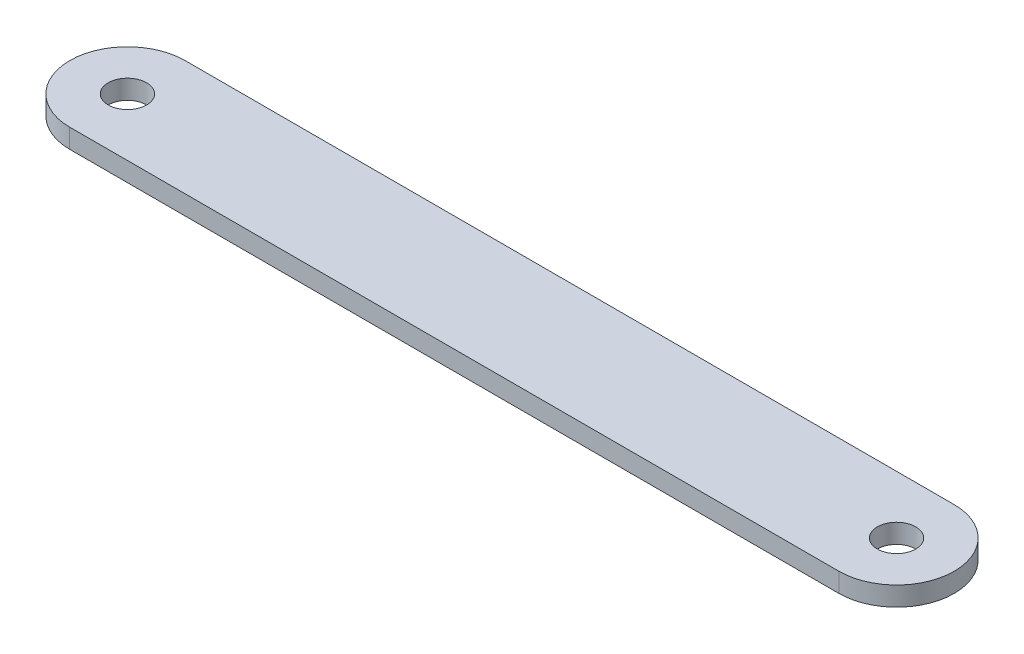
from build123d import *

# Parameters (mm, degrees)
SKETCH_1_R      = 5
EXTRUDE_1_DEPTH = 5


with BuildPart() as part:
    # 草图1 → 凸台-拉伸1 (new body)
    with BuildSketch(Plane(origin=(0, 0, 0), x_dir=(1, 0, 0), z_dir=(0, 1, 0))):
        with BuildLine():
            Line((0, 15), (200, 15))
            ThreePointArc((200, 15), (215, 0), (200, -15))
            Line((200, -15), (0, -15))
            ThreePointArc((0, -15), (-15, 0), (0, 15))
        make_face()
        Circle(SKETCH_1_R, mode=Mode.SUBTRACT)
        with Locations((200, 0)):
            Circle(SKETCH_1_R, mode=Mode.SUBTRACT)
    extrude(amount=EXTRUDE_1_DEPTH)


solid = part.part
